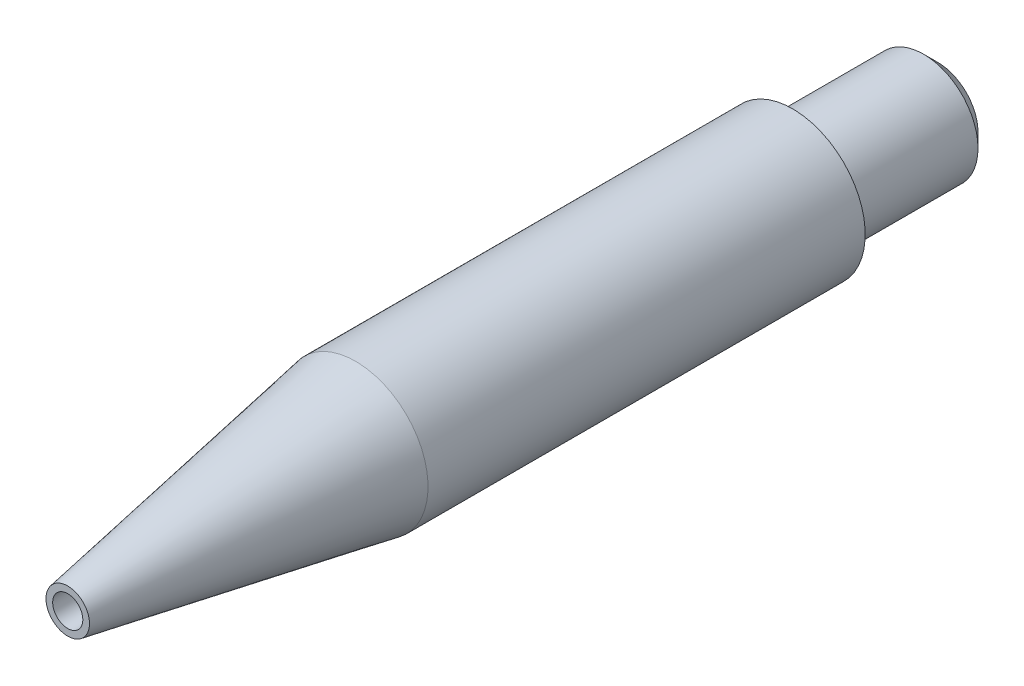
from build123d import *

# Parameters (mm, degrees)
SKETCH1_R                       = 6.35
BOSS_EXTRUDE1_DEPTH             = 76.2
SKETCH8_R                       = 1.3208
CUT_EXTRUDE1_DEPTH              = 77.2
SKETCH10_R                      = 6.35
SKETCH10_R_2                    = 4.7625
CUT_EXTRUDE2_DEPTH              = 12.7
F_1_4_0_25_DIAMETER_HOLE1_D     = 6.35
F_1_4_0_25_DIAMETER_HOLE1_DEPTH = 63.5
F_1_4_0_25_DIAMETER_HOLE1_TIP   = 1.907732465


with BuildPart() as part:
    # Sketch1 → Boss-Extrude1 (new body)
    with BuildSketch(Plane.XY):
        Circle(SKETCH1_R)
    extrude(amount=BOSS_EXTRUDE1_DEPTH)

    # Sketch7 → Cut-Revolve1 (revolve, cut)
    with BuildSketch(Plane(origin=(0, 0, 0), x_dir=(1, 0, 0), z_dir=(0, 1, 0))):
        Polygon((6.35, -76.2), (6.35, -50.991152312), (1.905, -76.2), align=None)
    revolve(axis=Axis((0, 0, -47.573976859), (0, 0, 1)), mode=Mode.SUBTRACT)

    # Sketch8 → Cut-Extrude1 (cut, through all)
    with BuildSketch(Plane.XY.offset(76.2)):
        Circle(SKETCH8_R)
    extrude(amount=-CUT_EXTRUDE1_DEPTH, mode=Mode.SUBTRACT)

    # Sketch10 → Cut-Extrude2 (cut)
    with BuildSketch(Plane(origin=(0, 0, 0), x_dir=(-1, 0, 0), z_dir=(0, 0, -1))):
        Circle(SKETCH10_R)
        Circle(SKETCH10_R_2, mode=Mode.SUBTRACT)
    extrude(amount=-CUT_EXTRUDE2_DEPTH, mode=Mode.SUBTRACT)

    # 1/4 (0.25) Diameter Hole1
    with Locations(Plane(origin=(0, 0, 0), x_dir=(-1, 0, 0), z_dir=(0, 0, -1))):
        with Locations((0, 0)):
            Hole(F_1_4_0_25_DIAMETER_HOLE1_D / 2, depth=F_1_4_0_25_DIAMETER_HOLE1_DEPTH)
            with Locations((0, 0, -(F_1_4_0_25_DIAMETER_HOLE1_DEPTH + F_1_4_0_25_DIAMETER_HOLE1_TIP / 2))):  # 118° drill point
                Cone(0, F_1_4_0_25_DIAMETER_HOLE1_D / 2, F_1_4_0_25_DIAMETER_HOLE1_TIP, mode=Mode.SUBTRACT)

    # Sketch18 → Cut-Revolve2 (revolve, cut)
    with BuildSketch(Plane(origin=(0, 0, 0), x_dir=(1, 0, 0), z_dir=(0, 1, 0))):
        with BuildLine():
            Line((4.7625, -12.7), (4.1656, -12.7))
            ThreePointArc((4.1656, -12.7), (3.6576, -12.192), (4.1656, -11.684))
            Line((4.1656, -11.684), (4.7625, -11.684))
            Line((4.7625, -11.684), (4.7625, -12.7))
        make_face()
    revolve(axis=Axis((0, 0, 0.466216552), (0, 0, -1)), mode=Mode.SUBTRACT)

    # Sketch20 → Cut-Revolve3 (revolve, cut)
    with BuildSketch(Plane(origin=(0, 0, 0), x_dir=(1, 0, 0), z_dir=(0, 1, 0))):
        Polygon((4.7625, 0), (4.7625, -1.2319), (3.5306, 0), align=None)
    revolve(axis=Axis((0, 0, 0.466216552), (0, 0, -1)), mode=Mode.SUBTRACT)


solid = part.part
